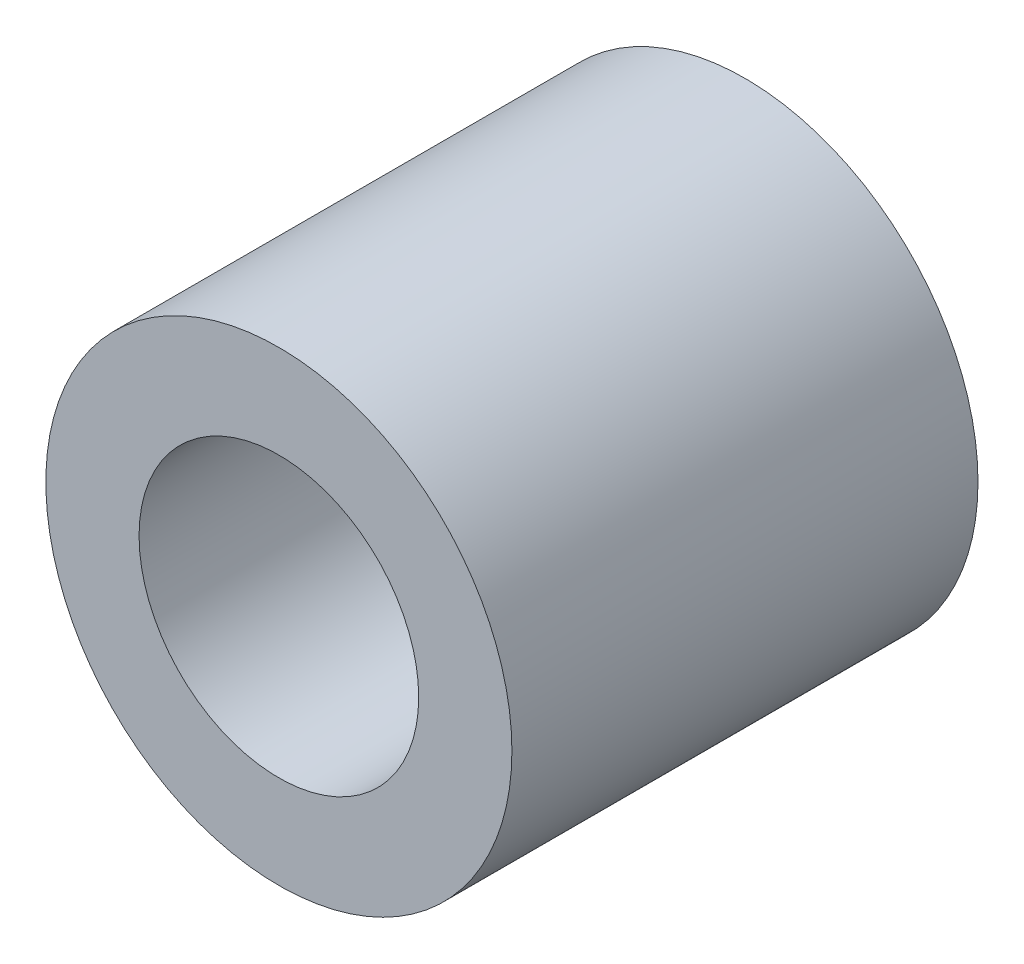
from build123d import *

# Parameters (mm, degrees)
SKETCH2_R           = 2.5
SKETCH2_R_2         = 1.5
BOSS_EXTRUDE1_DEPTH = 5


with BuildPart() as part:
    # Sketch2 → Boss-Extrude1 (new body)
    with BuildSketch(Plane.XY):
        Circle(SKETCH2_R)
        Circle(SKETCH2_R_2, mode=Mode.SUBTRACT)
    extrude(amount=BOSS_EXTRUDE1_DEPTH)


solid = part.part
